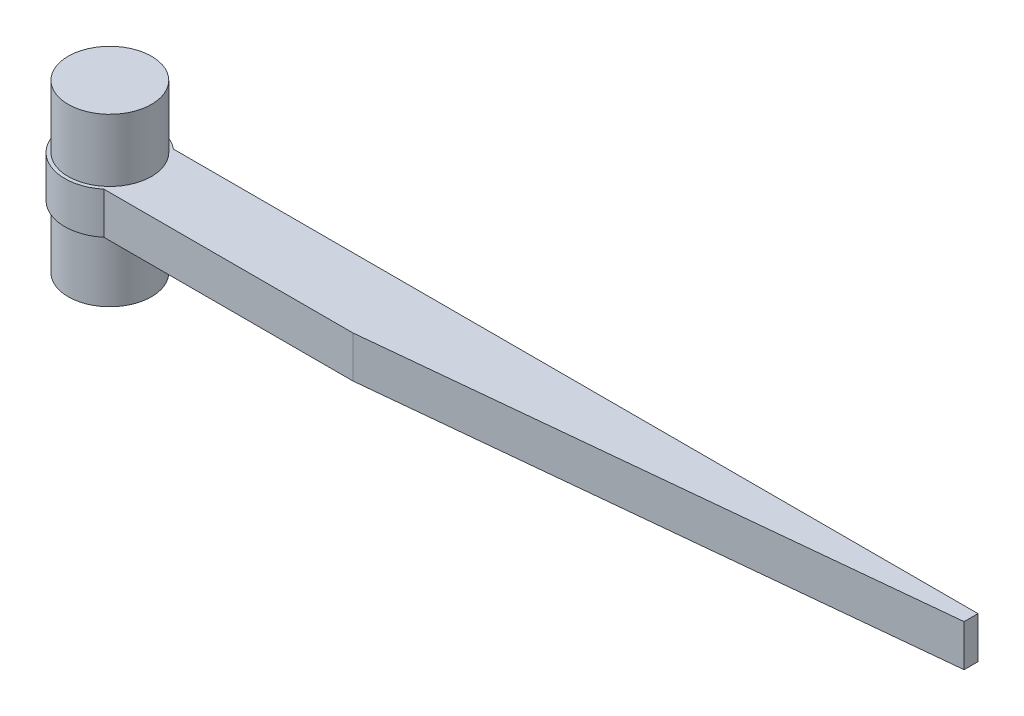
from build123d import *

# Parameters (mm, degrees)
SKETCH1_R           = 3.25
BOSS_EXTRUDE1_DEPTH = 1.5
SKETCH2_R           = 3
BOSS_EXTRUDE2_DEPTH = 6
SKETCH3_W           = 60
SKETCH3_H           = 3
BOSS_EXTRUDE3_DEPTH = 2.5
CHAMFER1_SIZE       = 4
CHAMFER1_SIZE2      = 40
SKETCH4_R           = 0.85
CUT_EXTRUDE1_DEPTH  = 0.5


with BuildPart() as part:
    # Sketch1 → Boss-Extrude1 (new body, symmetric)
    with BuildSketch(Plane(origin=(0, 0, 0), x_dir=(1, 0, 0), z_dir=(0, 1, 0))):
        Circle(SKETCH1_R)
    extrude(amount=BOSS_EXTRUDE1_DEPTH, both=True)

    # Sketch2 → Boss-Extrude2 (add, symmetric)
    with BuildSketch(Plane(origin=(0, 0, 0), x_dir=(1, 0, 0), z_dir=(0, 1, 0))):
        Circle(SKETCH2_R)
    extrude(amount=BOSS_EXTRUDE2_DEPTH, both=True)

    # Sketch3 → Boss-Extrude3 (add, symmetric)
    with BuildSketch(Plane.XY):
        with Locations((30, 0)):
            Rectangle(SKETCH3_W, SKETCH3_H)
    extrude(amount=BOSS_EXTRUDE3_DEPTH, both=True)

    # Chamfer1
    chamfer1_edges = [part.edges().sort_by_distance(p)[0] for p in [
        (60, 0, 2.5),
    ]]
    chamfer1_side = [part.faces().sort_by_distance(p)[0] for p in [
        (60, 0, 0),
    ]]
    chamfer(chamfer1_edges, length=CHAMFER1_SIZE, length2=CHAMFER1_SIZE2, reference=chamfer1_side[0])

    # Sketch4 → Cut-Extrude1 (cut)
    with BuildSketch(Plane(origin=(0, 0, -2.5), x_dir=(-1, 0, 0), z_dir=(0, 0, -1))):
        with Locations((-6.044728096, 0)):
            Circle(SKETCH4_R)
        with Locations((-11.044728096, 0)):
            Circle(SKETCH4_R)
        with Locations((-16.044728096, 0)):
            Circle(SKETCH4_R)
        with Locations((-21.044728096, 0)):
            Circle(SKETCH4_R)
        with Locations((-26.044728096, 0)):
            Circle(SKETCH4_R)
        with Locations((-31.044728096, 0)):
            Circle(SKETCH4_R)
        with Locations((-36.044728096, 0)):
            Circle(SKETCH4_R)
        with Locations((-41.044728096, 0)):
            Circle(SKETCH4_R)
        with Locations((-46.044728096, 0)):
            Circle(SKETCH4_R)
        with Locations((-51.044728096, 0)):
            Circle(SKETCH4_R)
        with Locations((-56.044728096, 0)):
            Circle(SKETCH4_R)
    extrude(amount=-CUT_EXTRUDE1_DEPTH, mode=Mode.SUBTRACT)


solid = part.part
